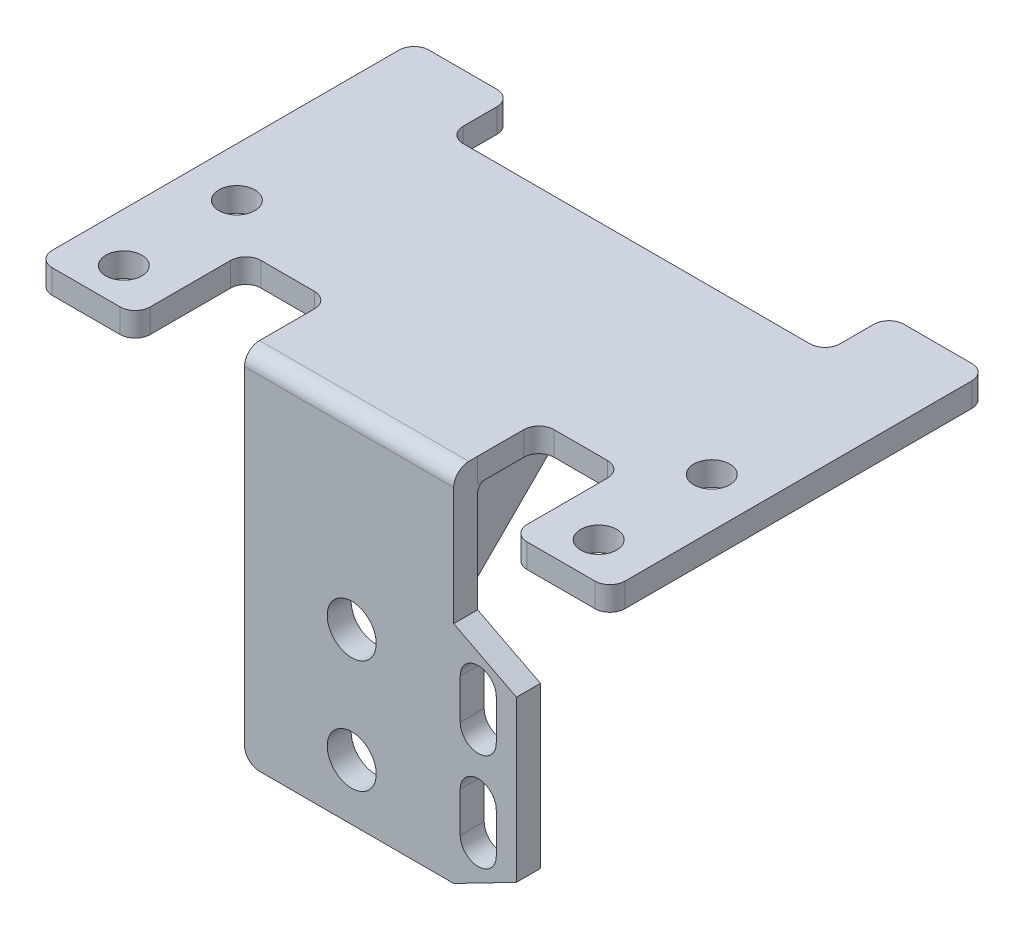
from build123d import *

# Parameters (mm, degrees)
BOSS_EXTRUDE2_DEPTH = 3.18
SKETCH8_R           = 3.25
BOSS_EXTRUDE3_DEPTH = 3.18
FILLET4_R           = 2
FILLET5_R           = 1
SKETCH9_R           = 2.39
CUT_EXTRUDE1_DEPTH  = 3.18
FILLET6_R           = 2
FILLET7_R           = 2
FILLET8_R           = 2
BOSS_EXTRUDE6_DEPTH = 10
SKETCH12_R          = 7.894491475
CUT_EXTRUDE2_DEPTH  = 20


with BuildPart() as part:
    # Sketch1 → Boss-Extrude2 (new body)
    with BuildSketch(Plane(origin=(0, 0, 0), x_dir=(1, 0, 0), z_dir=(0, 1, 0))):
        Polygon((0, 0), (0, 50), (13, 50), (13, 41.521912351), (63, 41.521912351), (63, 50), (76, 50), (76, 0), (63, 0), (63, 14.685258964), (51.88, 14.685258964), (51.88, 6.566903426), (24.12, 6.566903426), (24.12, 14.685258964), (13, 14.685258964), (13, 0), align=None)
    extrude(amount=-BOSS_EXTRUDE2_DEPTH)

    # Sketch8 → Boss-Extrude3 (add)
    with BuildSketch(Plane.XY.offset(-6.566903426)):
        with BuildLine():
            Line((24.12, -45.5), (24.12, -20.153398116))
            Line((24.12, -20.153398116), (24.12, 0))
            Line((24.12, 0), (51.879574545, 0))
            Line((51.879574545, 0), (51.879574545, -17.65))
            Line((51.879574545, -17.65), (60.204359999, -21.94))
            Line((60.204359999, -21.94), (60.204359999, -43.21))
            Line((60.204359999, -43.21), (51.879574545, -47.5))
            Line((51.879574545, -47.5), (26.12, -47.5))
            ThreePointArc((26.12, -47.5), (24.705786438, -46.914213562), (24.12, -45.5))
        make_face()
        with Locations((38.348750497, -25.08)):
            Circle(SKETCH8_R, mode=Mode.SUBTRACT)
        with Locations((38.348750497, -40.08)):
            Circle(SKETCH8_R, mode=Mode.SUBTRACT)
        with BuildLine():
            Line((57.524359999, -23.223501404), (57.524359999, -28.546918648))
            ThreePointArc((57.524359999, -28.546918648), (55.134359999, -30.936918648), (52.744359999, -28.546918648))
            Line((52.744359999, -28.546918648), (52.744359999, -23.223501404))
            ThreePointArc((52.744359999, -23.223501404), (55.134359999, -20.833501404), (57.524359999, -23.223501404))
        make_face(mode=Mode.SUBTRACT)
        with BuildLine():
            Line((57.524359999, -36.223501404), (57.524359999, -41.546918648))
            ThreePointArc((57.524359999, -41.546918648), (55.134359999, -43.936918648), (52.744359999, -41.546918648))
            Line((52.744359999, -41.546918648), (52.744359999, -36.223501404))
            ThreePointArc((52.744359999, -36.223501404), (55.134359999, -33.833501404), (57.524359999, -36.223501404))
        make_face(mode=Mode.SUBTRACT)
    extrude(amount=BOSS_EXTRUDE3_DEPTH)

    # Fillet4
    fillet4_edges = [part.edges().sort_by_distance(p)[0] for p in [
        (37.999787272, 0, -3.386903426),
    ]]
    fillet(fillet4_edges, radius=FILLET4_R)

    # Fillet5
    fillet5_edges = [part.edges().sort_by_distance(p)[0] for p in [
        (37.999787272, -3.18, -6.566903426),
    ]]
    fillet(fillet5_edges, radius=FILLET5_R)

    # Sketch9 → Cut-Extrude1 (cut)
    with BuildSketch(Plane(origin=(0, 0, 0), x_dir=(1, 0, 0), z_dir=(0, 1, 0))):
        with Locations((6.5, 5)):
            Circle(SKETCH9_R)
        with Locations((6.5, 20)):
            Circle(SKETCH9_R)
        with Locations((69.5, 20)):
            Circle(SKETCH9_R)
        with Locations((69.5, 5)):
            Circle(SKETCH9_R)
    extrude(amount=-CUT_EXTRUDE1_DEPTH, mode=Mode.SUBTRACT)

    # Fillet6
    fillet6_edges = [part.edges().sort_by_distance(p)[0] for p in [
        (0, -1.59, 0),
    ]]
    fillet(fillet6_edges, radius=FILLET6_R)

    # Fillet7
    fillet7_edges = [part.edges().sort_by_distance(p)[0] for p in [
        (13, -1.59, 0),
    ]]
    fillet(fillet7_edges, radius=FILLET7_R)

    # Fillet8
    fillet8_edges = [part.edges().sort_by_distance(p)[0] for p in [
        (0, -1.59, -50),
        (13, -1.59, -50),
        (13, -1.59, -41.521912351),
        (63, -1.59, -41.521912351),
        (63, -1.59, -50),
        (76, -1.59, -50),
        (76, -1.59, 0),
        (63, -1.59, 0),
        (63, -1.59, -14.685258964),
        (51.88, -1.59, -14.685258964),
        (24.12, -1.59, -14.685258964),
        (13, -1.59, -14.685258964),
    ]]
    fillet(fillet8_edges, radius=FILLET8_R)

    # Sketch11 → Boss-Extrude6 (add, symmetric)
    with BuildSketch(Plane(origin=(38, 0, 0), x_dir=(0, 0, -1), z_dir=(1, 0, 0))):
        Polygon((25, -3.18), (6.54535076, -3.18), (6.54535076, -21.63464924), align=None)
    extrude(amount=BOSS_EXTRUDE6_DEPTH, both=True)

    # Sketch12 → Cut-Extrude2 (cut)
    with BuildSketch(Plane(origin=(0, 0, -6.566903426), x_dir=(-1, 0, 0), z_dir=(0, 0, -1))):
        with Locations((-38.348750497, -25.08)):
            Circle(SKETCH12_R)
    extrude(amount=CUT_EXTRUDE2_DEPTH, mode=Mode.SUBTRACT)


solid = part.part
